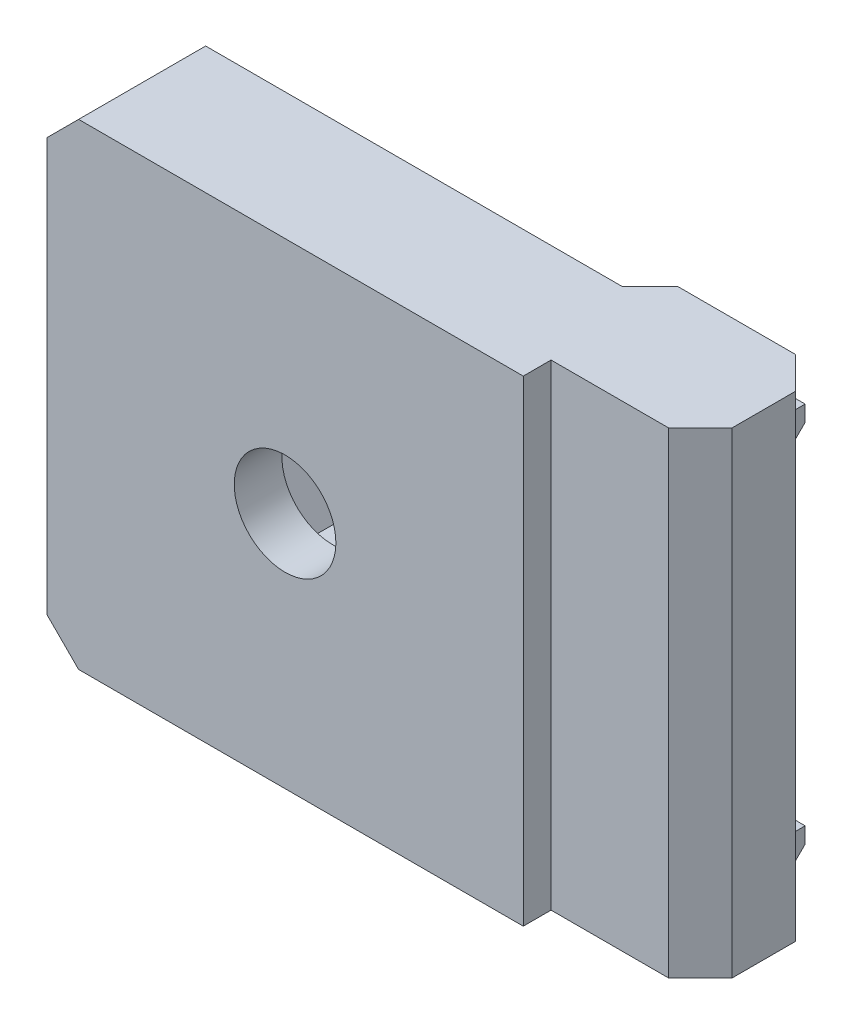
from build123d import *

# Parameters (mm, degrees)
SALIENTE_EXTRUIR1_DEPTH = 15
CROQUIS2_R              = 3.2
CORTAR_EXTRUIR1_DEPTH   = 10.75
CORTAR_EXTRUIR2_START   = -3
CORTAR_EXTRUIR2_DEPTH   = 7.75
CHAFL_N1_SIZE           = 2
SALIENTE_EXTRUIR3_DEPTH = 7.4


with BuildPart() as part:
    # Croquis1 → Saliente-Extruir1 (new body, symmetric)
    with BuildSketch(Plane(origin=(0, 0, 0), x_dir=(1, 0, 0), z_dir=(0, 1, 0))):
        Polygon((0, 0), (-30, 0), (-30, 8), (-1.75, 8), (0, 9.75), (9.4, 9.75), (9.4, 1.75), (0, 1.75), align=None)
    extrude(amount=SALIENTE_EXTRUIR1_DEPTH, both=True)

    # Croquis2 → Cortar-Extruir1 (cut, through all)
    with BuildSketch(Plane.XY):
        with Locations((-15, 0)):
            Circle(CROQUIS2_R)
    extrude(amount=-CORTAR_EXTRUIR1_DEPTH, mode=Mode.SUBTRACT)

    # Croquis3 → Cortar-Extruir2 (cut, through all)
    with BuildSketch(Plane.XY.offset(CORTAR_EXTRUIR2_START)):
        Polygon((-9.226497308, 0), (-12.113248654, 5), (-17.886751346, 5), (-20.773502692, 0), (-17.886751346, -5), (-12.113248654, -5), align=None)
    extrude(amount=-CORTAR_EXTRUIR2_DEPTH, mode=Mode.SUBTRACT)

    # Chaflán1
    chafl_n1_edges = [part.edges().sort_by_distance(p)[0] for p in [
        (9.4, 0, -9.75),
        (9.4, 0, -1.75),
        (-30, 15, -4),
        (-30, -15, -4),
    ]]
    chamfer(chafl_n1_edges, length=CHAFL_N1_SIZE)

    # Croquis5 → Saliente-Extruir3 (add)
    with BuildSketch(Plane(origin=(0, 0, 0), x_dir=(0, 0, -1), z_dir=(1, 0, 0))):
        Polygon((9.75, 12), (10.35, 12), (10.35, 11), (9.75, 10.4), align=None)
        Polygon((9.75, -11), (10.35, -11), (10.35, -12), (9.75, -12.6), align=None)
    extrude(amount=SALIENTE_EXTRUIR3_DEPTH)


solid = part.part
